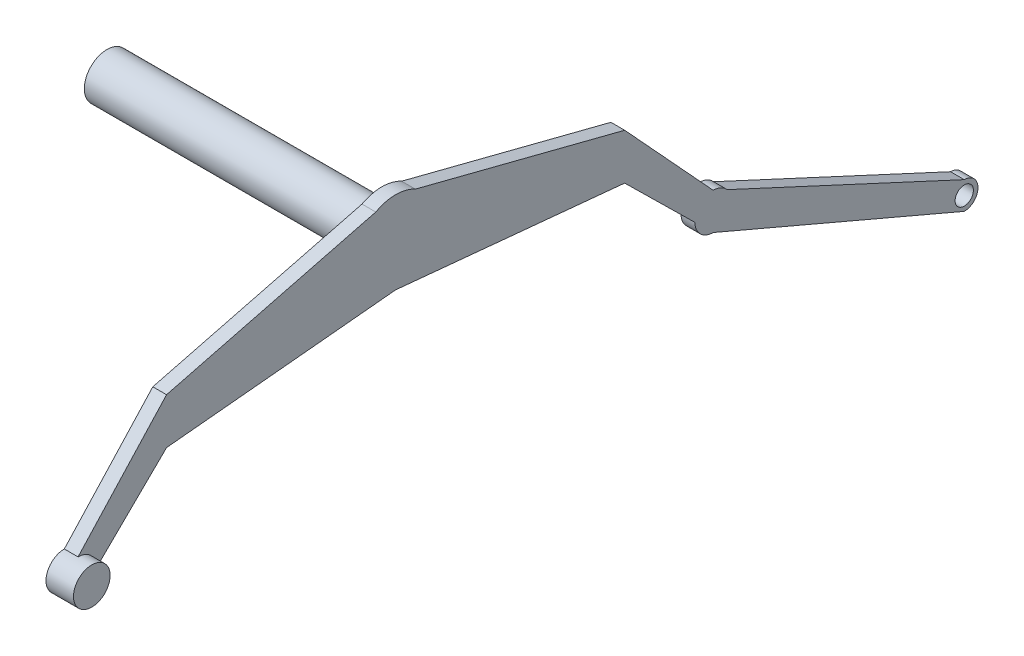
from build123d import *

# Parameters (mm, degrees)
SKETCH1_R           = 20
BOSS_EXTRUDE1_DEPTH = 30
SKETCH1_3_R         = 40
BOSS_EXTRUDE2_DEPTH = 60
SKETCH1_4_R         = 49.5
BOSS_EXTRUDE3_DEPTH = 600


with BuildPart() as part:
    # Sketch1 → Boss-Extrude1 (new body)
    with BuildSketch(Plane(origin=(0, 0, 0), x_dir=(0, 0, -1), z_dir=(1, 0, 0))):
        with BuildLine():
            Line((-500, -38.163490354), (-693.137754961, -248.163490354))
            ThreePointArc((-693.137754961, -248.163490354), (-721.652707583, -316.215183298), (-653.1431202, -288.818616504))
            Line((-653.1431202, -288.818616504), (-500, -138.163490354))
            Line((-500, -138.163490354), (0, -90))
            Line((0, -90), (500, -138.163490354))
            Line((500, -138.163490354), (653.1431202, -288.818616504))
            ThreePointArc((653.1431202, -288.818616504), (665.086062018, -316.678442975), (693.137754961, -328.163490354))
            Line((693.137754961, -328.163490354), (1241.260569265, -562.203490354))
            ThreePointArc((1241.260569265, -562.203490354), (1271.260569265, -532.203490354), (1241.260569265, -502.203490354))
            Line((1241.260569265, -502.203490354), (723.659328701, -262.309408733))
            ThreePointArc((723.659328701, -262.309408733), (709.957932356, -251.87187104), (693.137754961, -248.163490354))
            Line((693.137754961, -248.163490354), (500, -38.163490354))
            Line((500, -38.163490354), (43.294270514, 78.902510357))
            ThreePointArc((43.294270514, 78.902510357), (0, 90), (-43.294270514, 78.902510357))
            Line((-43.294270514, 78.902510357), (-500, -38.163490354))
        make_face()
        with Locations((1241.260569265, -532.203490354)):
            Circle(SKETCH1_R, mode=Mode.SUBTRACT)
    extrude(amount=BOSS_EXTRUDE1_DEPTH)

    # Sketch1_3 → Boss-Extrude2 (add)
    with BuildSketch(Plane(origin=(0, 0, 0), x_dir=(0, 0, -1), z_dir=(1, 0, 0))):
        with Locations((-693.137754961, -288.163490354)):
            Circle(SKETCH1_3_R)
    extrude(amount=BOSS_EXTRUDE2_DEPTH)

    # Sketch1_4 → Boss-Extrude3 (add)
    with BuildSketch(Plane(origin=(0, 0, 0), x_dir=(0, 0, -1), z_dir=(1, 0, 0))):
        Circle(SKETCH1_4_R)
    extrude(amount=-BOSS_EXTRUDE3_DEPTH)


solid = part.part
